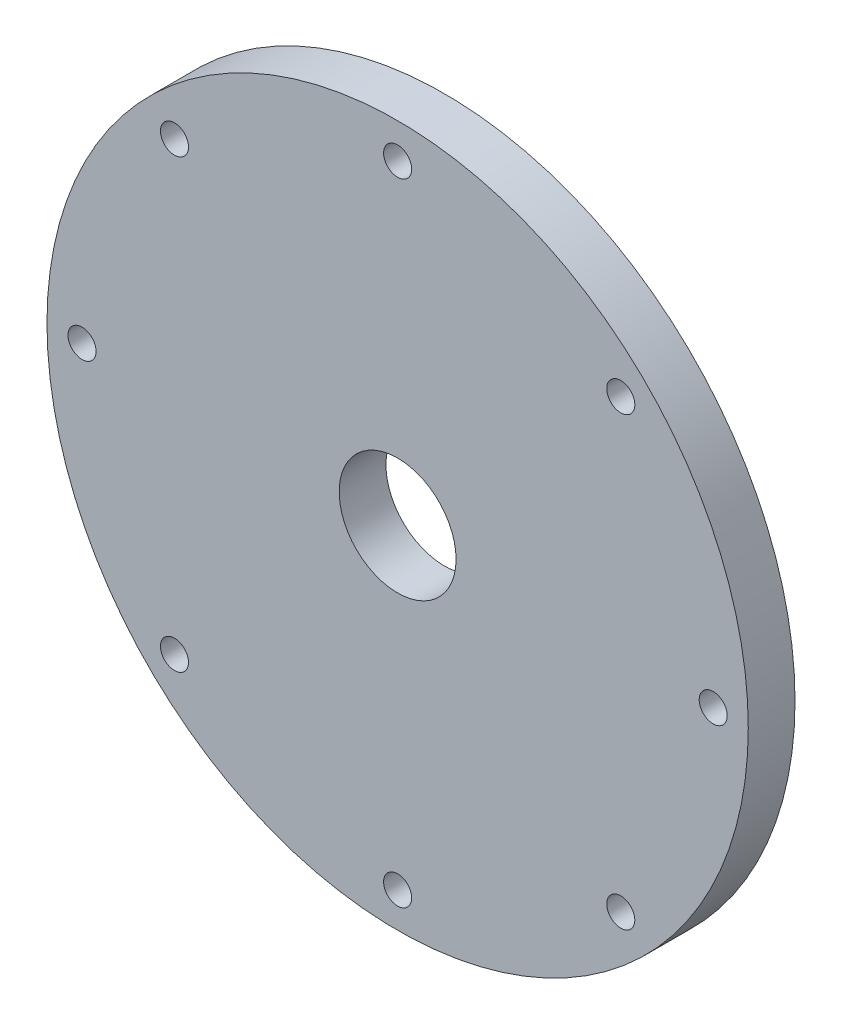
from build123d import *

# Parameters (mm, degrees)
CROQUIS1_R              = 75
CROQUIS1_R_2            = 3
CROQUIS1_R_3            = 12.5
SALIENTE_EXTRUIR1_DEPTH = 10


with BuildPart() as part:
    # Croquis1 → Saliente-Extruir1 (new body)
    with BuildSketch(Plane.XY):
        Circle(CROQUIS1_R)
        with Locations((0, 67.5)):
            Circle(CROQUIS1_R_2, mode=Mode.SUBTRACT)
        with Locations((47.72970773, 47.72970773)):
            Circle(CROQUIS1_R_2, mode=Mode.SUBTRACT)
        with Locations((67.5, 0)):
            Circle(CROQUIS1_R_2, mode=Mode.SUBTRACT)
        with Locations((47.72970773, -47.72970773)):
            Circle(CROQUIS1_R_2, mode=Mode.SUBTRACT)
        with Locations((0, -67.5)):
            Circle(CROQUIS1_R_2, mode=Mode.SUBTRACT)
        with Locations((-47.72970773, -47.72970773)):
            Circle(CROQUIS1_R_2, mode=Mode.SUBTRACT)
        with Locations((-67.5, 0)):
            Circle(CROQUIS1_R_2, mode=Mode.SUBTRACT)
        with Locations((-47.72970773, 47.72970773)):
            Circle(CROQUIS1_R_2, mode=Mode.SUBTRACT)
        Circle(CROQUIS1_R_3, mode=Mode.SUBTRACT)
    extrude(amount=SALIENTE_EXTRUIR1_DEPTH)


solid = part.part
